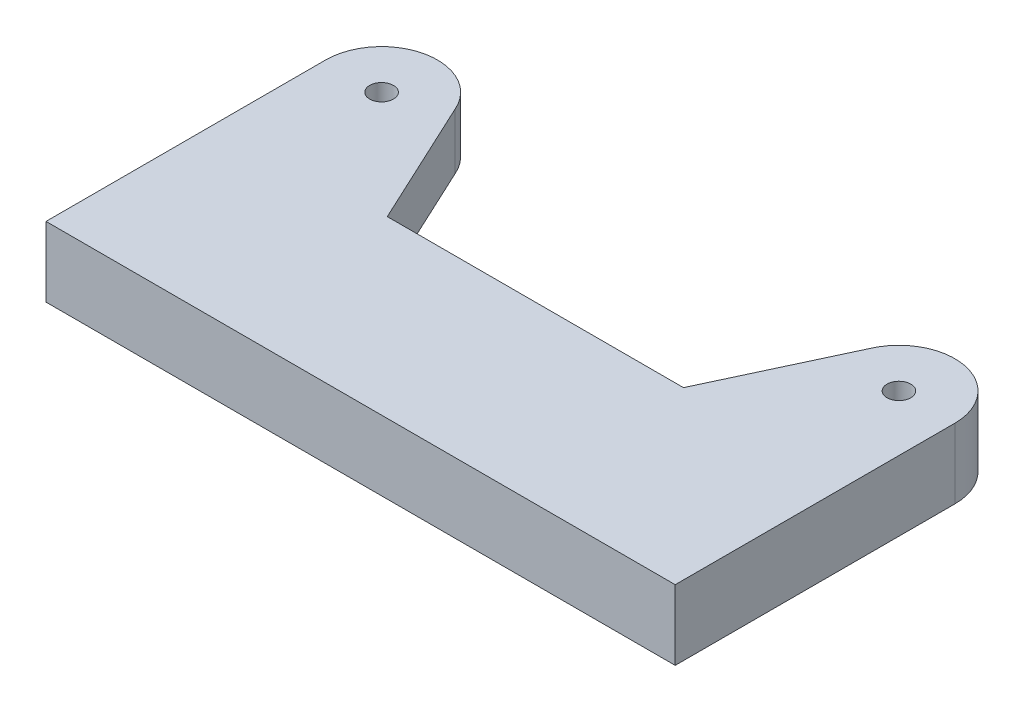
from build123d import *

# Parameters (mm, degrees)
BOSS_EXTRUDE1_DEPTH      = 10
SKETCH2_W                = 85
SKETCH2_H                = 33
CUT_EXTRUDE1_DEPTH       = 2
FILLET1_R                = 1
M3_CLEARANCE_HOLE1_D     = 3.4
M3_CLEARANCE_HOLE1_DEPTH = 8
M3_CLEARANCE_HOLE1_TIP   = 1.021463052


with BuildPart() as part:
    # Sketch1 → Boss-Extrude1 (new body)
    with BuildSketch(Plane(origin=(0, 0, 0), x_dir=(1, 0, 0), z_dir=(0, 1, 0))):
        with BuildLine():
            Line((45, 0), (-45, 0))
            Line((-45, 0), (-45, 40))
            ThreePointArc((-45, 40), (-38.595106732, 47.83936442), (-29.636091372, 43.126155741))
            Line((-29.636091372, 43.126155741), (-21.183726137, 25))
            Line((-21.183726137, 25), (21.183726137, 25))
            Line((21.183726137, 25), (29.636091372, 43.126155741))
            ThreePointArc((29.636091372, 43.126155741), (38.595106732, 47.83936442), (45, 40))
            Line((45, 40), (45, 0))
        make_face()
    extrude(amount=BOSS_EXTRUDE1_DEPTH)

    # Sketch2 → Cut-Extrude1 (cut)
    with BuildSketch(Plane.XZ):
        with Locations((0, -31.5)):
            Rectangle(SKETCH2_W, SKETCH2_H)
    extrude(amount=-CUT_EXTRUDE1_DEPTH, mode=Mode.SUBTRACT)

    # Fillet1
    fillet1_edges = [part.edges().sort_by_distance(p)[0] for p in [
        (42.5, 1, -15),
        (-42.5, 1, -15),
    ]]
    fillet(fillet1_edges, radius=FILLET1_R)

    # M3 Clearance Hole1
    with Locations(Plane(origin=(0, 10, 0), x_dir=(1, 0, 0), z_dir=(0, 1, 0))):
        with Locations((-37, 40), (37, 40)):
            Hole(M3_CLEARANCE_HOLE1_D / 2, depth=M3_CLEARANCE_HOLE1_DEPTH)
            with Locations((0, 0, -(M3_CLEARANCE_HOLE1_DEPTH + M3_CLEARANCE_HOLE1_TIP / 2))):  # 118° drill point
                Cone(0, M3_CLEARANCE_HOLE1_D / 2, M3_CLEARANCE_HOLE1_TIP, mode=Mode.SUBTRACT)


solid = part.part
